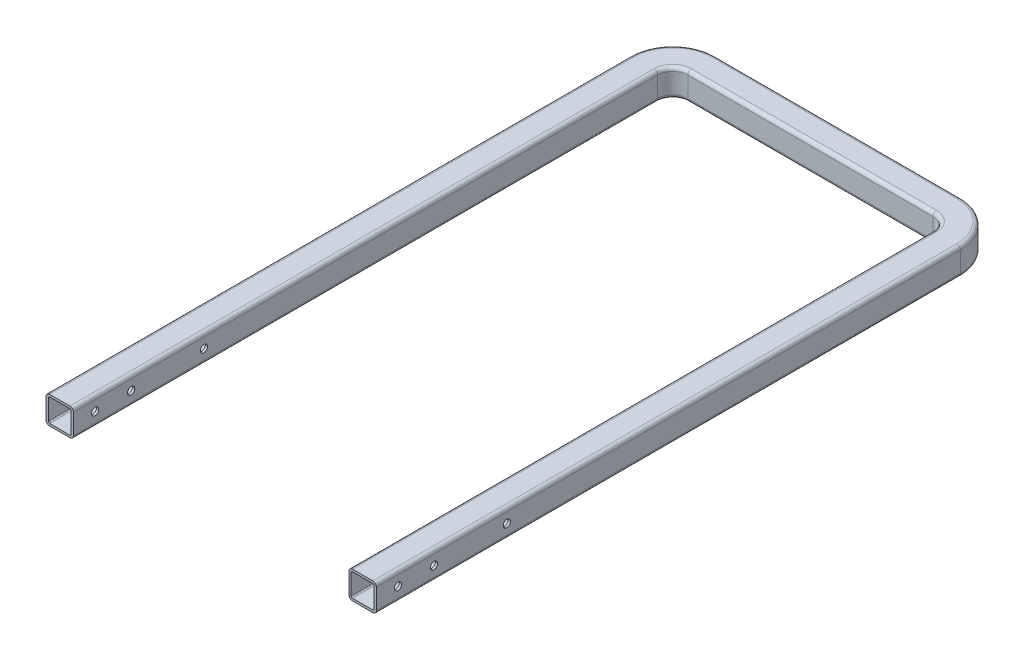
from build123d import *

# Parameters (mm, degrees)
SKETCH4_R               = 5
CUT_EXTRUDE2_DEPTH      = 440.0500001
CUT_EXTRUDE2_DEPTH_BACK = 20.0500001


with BuildPart() as part:
    # Sweep-Thin1: sweep along a path in Sketch1
    with BuildLine(Plane(origin=(0, 0, 0), x_dir=(1, 0, 0), z_dir=(0, 1, 0))) as sweep_thin1_path:
        Line((0, 0), (0, 810))
        ThreePointArc((0, 810), (11.715728753, 838.284271247), (40, 850))
        Line((40, 850), (380, 850))
        ThreePointArc((380, 850), (408.284271247, 838.284271247), (420, 810))
        Line((420, 810), (420, 0))
    # Sketch3 → Sweep-Thin1 (sweep)
    with BuildSketch(Plane.XY):
        with BuildLine():
            Line((14.05, 19.05), (-14.05, 19.05))
            ThreePointArc((-14.05, 19.05), (-17.585533906, 17.585533906), (-19.05, 14.05))
            Line((-19.05, 14.05), (-19.05, -14.05))
            ThreePointArc((-19.05, -14.05), (-17.585533906, -17.585533906), (-14.05, -19.05))
            Line((-14.05, -19.05), (14.05, -19.05))
            ThreePointArc((14.05, -19.05), (17.585533906, -17.585533906), (19.05, -14.05))
            Line((19.05, -14.05), (19.05, 14.05))
            ThreePointArc((19.05, 14.05), (17.585533906, 17.585533906), (14.05, 19.05))
        make_face()
        with BuildLine():
            Line((14.05, 15.875), (-14.05, 15.875))
            ThreePointArc((-14.05, 15.875), (-15.340469876, 15.340469876), (-15.875, 14.05))
            Line((-15.875, 14.05), (-15.875, -14.05))
            ThreePointArc((-15.875, -14.05), (-15.340469876, -15.340469876), (-14.05, -15.875))
            Line((-14.05, -15.875), (14.05, -15.875))
            ThreePointArc((14.05, -15.875), (15.340469876, -15.340469876), (15.875, -14.05))
            Line((15.875, -14.05), (15.875, 14.05))
            ThreePointArc((15.875, 14.05), (15.340469876, 15.340469876), (14.05, 15.875))
        make_face(mode=Mode.SUBTRACT)
    sweep(path=sweep_thin1_path.line)

    # Sketch4 → Cut-Extrude2 (cut, two sides)
    with BuildSketch(Plane(origin=(0, 0, 0), x_dir=(0, 0, -1), z_dir=(1, 0, 0))) as cut_extrude2_sk:
        with Locations((30, 0)):
            Circle(SKETCH4_R)
        with Locations((80, 0)):
            Circle(SKETCH4_R)
        with Locations((180.955115779, 0)):
            Circle(SKETCH4_R)
    extrude(amount=CUT_EXTRUDE2_DEPTH, mode=Mode.SUBTRACT)
    extrude(cut_extrude2_sk.sketch, amount=-CUT_EXTRUDE2_DEPTH_BACK, mode=Mode.SUBTRACT)


solid = part.part
